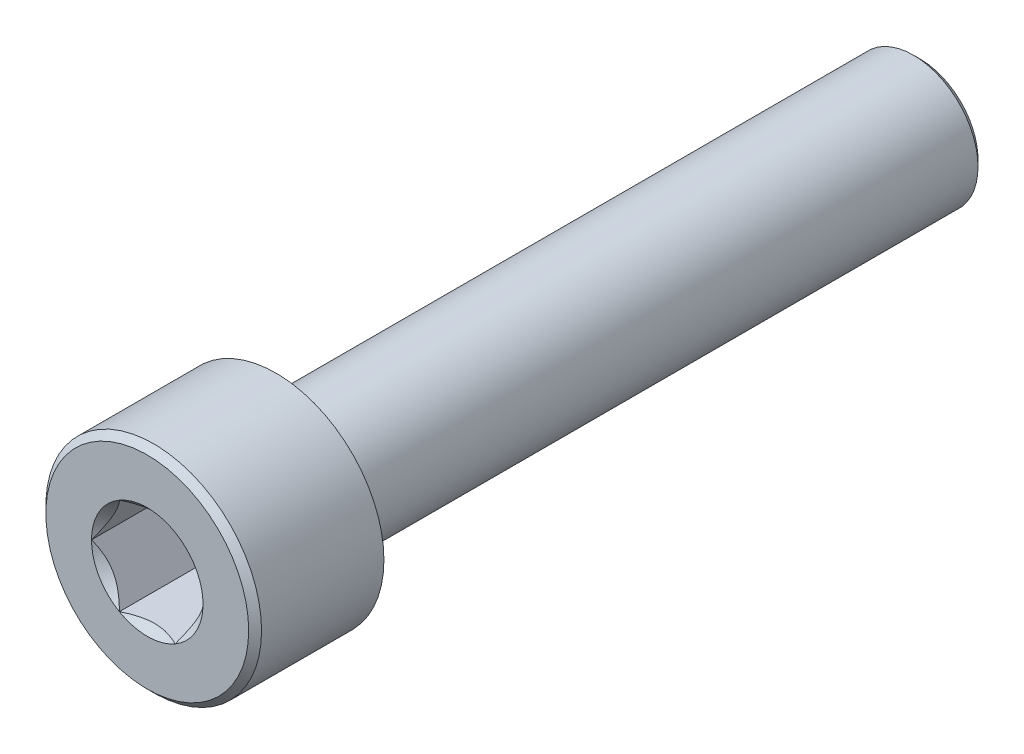
from build123d import *

# Parameters (mm, degrees)
SKETCH_1_R          = 3.35
EXTRUDE_1_DEPTH     = 4
CUT_EXTRUDE_1_DEPTH = 2.8
SKETCH_3_R          = 2
EXTRUDE_2_DEPTH     = 20
SKETCH_4_R          = 1.732050808
CUT_EXTRUDE_2_DEPTH = 2
CUT_EXTRUDE_2_DRAFT = -45
CHAMFER_1_SIZE      = 0.2


with BuildPart() as part:
    # Эскиз1 → Бобышка-Вытянуть1 (new body)
    with BuildSketch(Plane.XY):
        Circle(SKETCH_1_R)
    extrude(amount=EXTRUDE_1_DEPTH)

    # Эскиз2 → Вырез-Вытянуть1 (cut)
    with BuildSketch(Plane.XY.offset(4)):
        Polygon((1.732050808, 0), (0.866025404, 1.5), (-0.866025404, 1.5), (-1.732050808, 0), (-0.866025404, -1.5), (0.866025404, -1.5), align=None)
    extrude(amount=-CUT_EXTRUDE_1_DEPTH, mode=Mode.SUBTRACT)

    # Эскиз3 → Бобышка-Вытянуть2 (add)
    with BuildSketch(Plane(origin=(0, 0, 0), x_dir=(-1, 0, 0), z_dir=(0, 0, -1))):
        Circle(SKETCH_3_R)
    extrude(amount=EXTRUDE_2_DEPTH)


with BuildPart() as cut_extrude_2_tool:
    # Эскиз4 → Вырез-Вытянуть2 (with draft: the straight prism first)
    with BuildSketch(Plane.XY.offset(4)):
        Circle(SKETCH_4_R)
    extrude(amount=-CUT_EXTRUDE_2_DEPTH)
    # Вырез-Вытянуть2: the draft: its side faces are tilted about the plane it starts from
    cut_extrude_2_sides = [cut_extrude_2_tool.faces().sort_by_distance(p)[0] for p in [
        (-1.732050808, 0, 3),
    ]]
    draft(cut_extrude_2_sides, Plane.XY.offset(4), CUT_EXTRUDE_2_DRAFT)


with BuildPart() as part_1:
    add(part.part)

    # Вырез-Вытянуть2: cut by cut_extrude_2_tool
    add(cut_extrude_2_tool.part, mode=Mode.SUBTRACT)

    # Фаска1
    chamfer_1_edges = [part_1.edges().sort_by_distance(p)[0] for p in [
        (2, 0, -20),
        (-3.35, 0, 4),
    ]]
    chamfer(chamfer_1_edges, length=CHAMFER_1_SIZE)


solid = part_1.part
